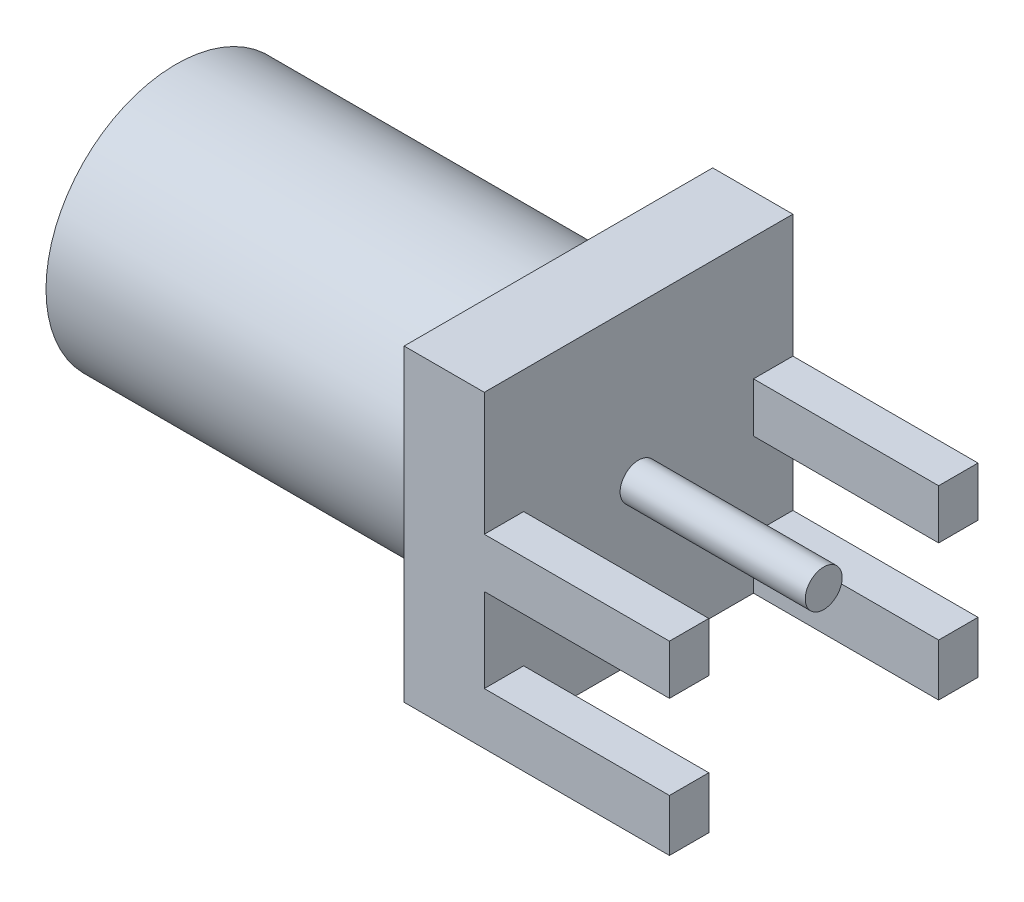
from build123d import *

# Parameters (mm, degrees)
SKETCH1_W           = 6.35
SKETCH1_H           = 6.35
BOSS_EXTRUDE1_DEPTH = 1.65
SKETCH2_W           = 3.81
SKETCH2_H           = 1.07
SKETCH2_H_2         = 1.02
BOSS_EXTRUDE2_DEPTH = 0.81
SKETCH3_R           = 0.38
BOSS_EXTRUDE3_DEPTH = 3.81
SKETCH4_R           = 2.675
BOSS_EXTRUDE4_DEPTH = 7.87


with BuildPart() as part:
    # Sketch1 → Boss-Extrude1 (new body)
    with BuildSketch(Plane(origin=(0, 0, 0), x_dir=(0, 0, -1), z_dir=(1, 0, 0))):
        Rectangle(SKETCH1_W, SKETCH1_H)
    extrude(amount=-BOSS_EXTRUDE1_DEPTH)

    # Sketch2 → Boss-Extrude2 (add)
    with BuildSketch(Plane(origin=(0, 0, -3.175), x_dir=(-1, 0, 0), z_dir=(0, 0, -1))):
        with Locations((-1.905, -2.64)):
            Rectangle(SKETCH2_W, SKETCH2_H)
        with Locations((-1.905, 0.135)):
            Rectangle(SKETCH2_W, SKETCH2_H_2)
    boss_extrude2 = extrude(amount=-BOSS_EXTRUDE2_DEPTH)

    # Mirror1: Boss-Extrude2 across plane
    add(boss_extrude2.mirror(Plane.XY))

    # Sketch3 → Boss-Extrude3 (add)
    with BuildSketch(Plane(origin=(0, 0, 0), x_dir=(0, 0, -1), z_dir=(1, 0, 0))):
        with Locations(Location((0, 0, 0), (0, 0, 180))):  # turned: the seam where the file's is
            Circle(SKETCH3_R)
    extrude(amount=BOSS_EXTRUDE3_DEPTH)

    # Sketch4 → Boss-Extrude4 (add)
    with BuildSketch(Plane.ZY.offset(1.65)):
        Circle(SKETCH4_R)
    extrude(amount=BOSS_EXTRUDE4_DEPTH)


solid = part.part
